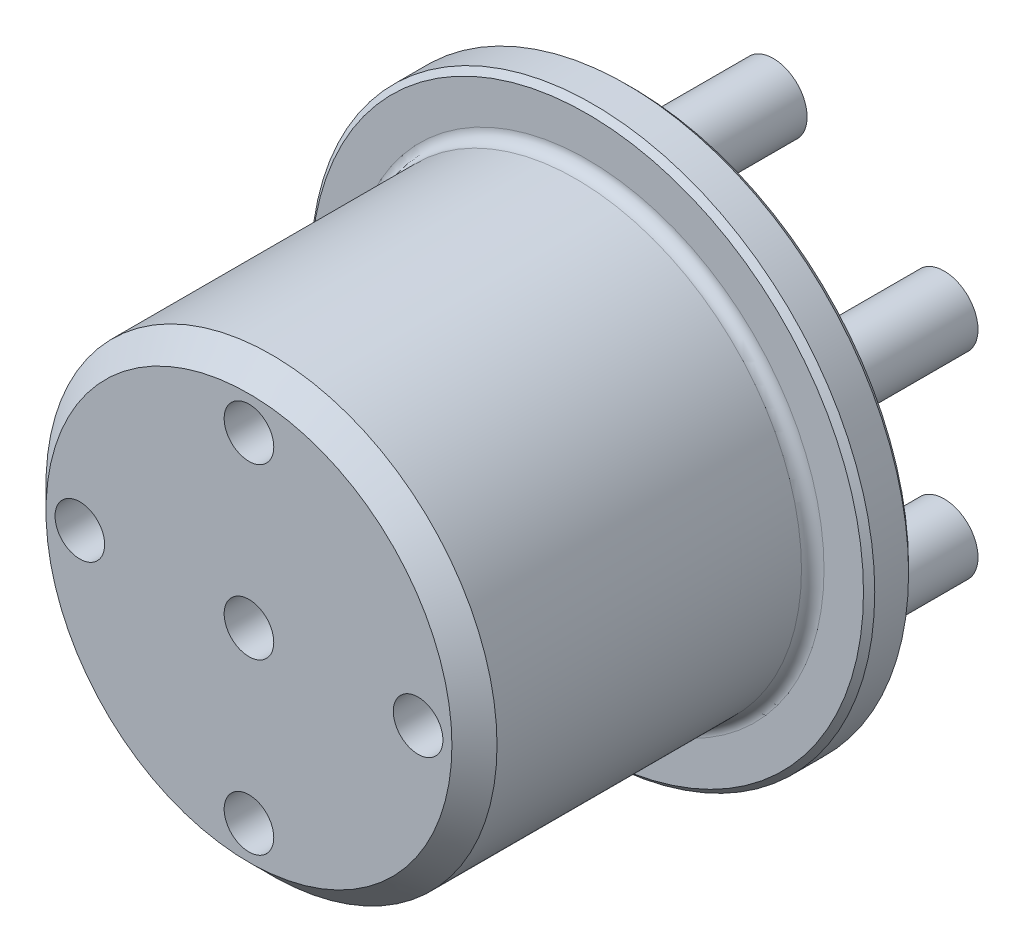
from build123d import *

# Parameters (mm, degrees)
SKETCH1_R                 = 25
BOSS_EXTRUDE1_DEPTH       = 4
SKETCH2_R                 = 20
BOSS_EXTRUDE2_DEPTH       = 30
FILLET1_R                 = 1
SKETCH3_R                 = 10.2
CUT_EXTRUDE1_DEPTH        = 5
SKETCH4_R                 = 3
BOSS_EXTRUDE3_DEPTH       = 12.5
F_4_0MM_DOWEL_HOLE1_D     = 4.4
F_4_0MM_DOWEL_HOLE1_DEPTH = 8
F_4_0MM_DOWEL_HOLE1_TIP   = 1.321893362
FILLET2_R                 = 1
CHAMFER1_SIZE             = 0.5
CHAMFER2_SIZE             = 2


with BuildPart() as part:
    # Sketch1 → Boss-Extrude1 (new body)
    with BuildSketch(Plane.XY):
        Circle(SKETCH1_R)
    extrude(amount=-BOSS_EXTRUDE1_DEPTH)

    # Sketch2 → Boss-Extrude2 (add)
    with BuildSketch(Plane.XY):
        Circle(SKETCH2_R)
    extrude(amount=BOSS_EXTRUDE2_DEPTH)

    # Fillet1
    fillet1_edges = [part.edges().sort_by_distance(p)[0] for p in [
        (-20, 0, 0),
    ]]
    fillet(fillet1_edges, radius=FILLET1_R)

    # Sketch3 → Cut-Extrude1 (cut)
    with BuildSketch(Plane(origin=(0, 0, -4), x_dir=(-1, 0, 0), z_dir=(0, 0, -1))):
        Circle(SKETCH3_R)
    extrude(amount=-CUT_EXTRUDE1_DEPTH, mode=Mode.SUBTRACT)

    # Sketch4 → Boss-Extrude3 (add)
    with BuildSketch(Plane(origin=(0, 0, -4), x_dir=(-1, 0, 0), z_dir=(0, 0, -1))):
        with Locations((0, 17.5)):
            Circle(SKETCH4_R)
        with Locations((15.155444566, 8.75)):
            Circle(SKETCH4_R)
        with Locations((15.155444566, -8.75)):
            Circle(SKETCH4_R)
        with Locations((0, -17.5)):
            Circle(SKETCH4_R)
        with Locations((-15.155444566, -8.75)):
            Circle(SKETCH4_R)
        with Locations((-15.155444566, 8.75)):
            Circle(SKETCH4_R)
    extrude(amount=BOSS_EXTRUDE3_DEPTH)

    # Ø4.0mm Dowel Hole1
    with Locations(Plane.XY.offset(30)):
        with Locations((0, 0), (0, 15), (15, 0), (0, -15), (-15, 0)):
            Hole(F_4_0MM_DOWEL_HOLE1_D / 2, depth=F_4_0MM_DOWEL_HOLE1_DEPTH)
            with Locations((0, 0, -(F_4_0MM_DOWEL_HOLE1_DEPTH + F_4_0MM_DOWEL_HOLE1_TIP / 2))):  # 118° drill point
                Cone(0, F_4_0MM_DOWEL_HOLE1_D / 2, F_4_0MM_DOWEL_HOLE1_TIP, mode=Mode.SUBTRACT)

    # Fillet2
    fillet2_edges = [part.edges().sort_by_distance(p)[0] for p in [
        (-12.155444566, 8.75, -4),
        (-12.155444566, -8.75, -4),
        (3, -17.5, -4),
        (18.155444566, 8.75, -4),
        (3, 17.5, -4),
        (18.155444566, -8.75, -4),
    ]]
    fillet(fillet2_edges, radius=FILLET2_R)

    # Chamfer1
    chamfer1_edges = [part.edges().sort_by_distance(p)[0] for p in [
        (10.2, 0, 1),
        (10.2, 0, -4),
        (-25, 0, 0),
        (-25, 0, -4),
    ]]
    chamfer(chamfer1_edges, length=CHAMFER1_SIZE)

    # Chamfer2
    chamfer2_edges = [part.edges().sort_by_distance(p)[0] for p in [
        (-20, 0, 30),
    ]]
    chamfer(chamfer2_edges, length=CHAMFER2_SIZE)


solid = part.part
